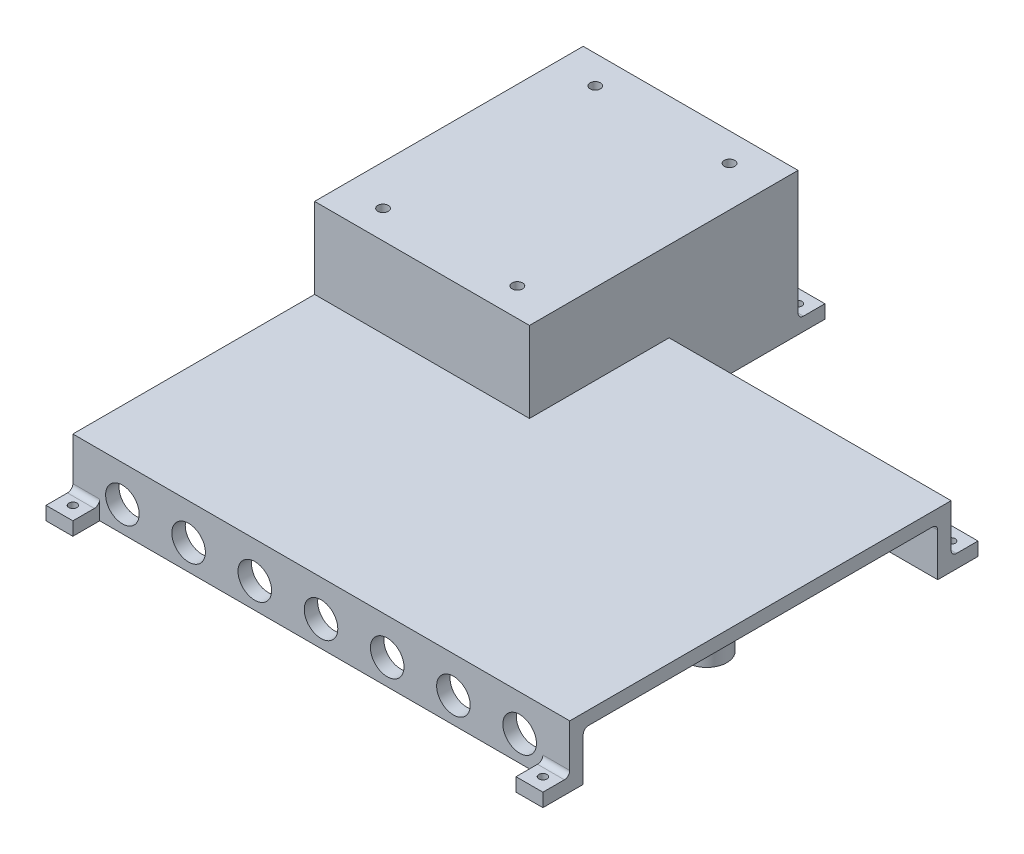
from build123d import *

# Parameters (mm, degrees)
SKETCH1_W            = 185
SKETCH1_H            = 142
BOSS_EXTRUDE1_DEPTH  = 23
SKETCH12_W           = 80
SKETCH12_H           = 100
BOSS_EXTRUDE6_DEPTH  = 53
SHELL1_T             = -5
SKETCH11_R           = 6.25
CUT_EXTRUDE2_DEPTH   = 6
FILLET1_R            = 2
SKETCH13_R           = 1.95
CUT_EXTRUDE3_DEPTH   = 54
SKETCH15_W           = 10
SKETCH15_H           = 5
BOSS_EXTRUDE8_DEPTH  = 10
SKETCH16_W           = 10
SKETCH16_H           = 5
BOSS_EXTRUDE9_DEPTH  = 10
SKETCH17_W           = 10
SKETCH17_H           = 5
BOSS_EXTRUDE10_DEPTH = 10
FILLET2_R            = 2
SKETCH18_R           = 1.5
CUT_EXTRUDE4_DEPTH   = 10
SKETCH19_R           = 7.5
BOSS_EXTRUDE11_DEPTH = 18
FILLET3_R            = 2


with BuildPart() as part:
    # Sketch1 → Boss-Extrude1 (new body)
    with BuildSketch(Plane(origin=(0, 0, 0), x_dir=(1, 0, 0), z_dir=(0, 1, 0))):
        with Locations((92.5, 71)):
            Rectangle(SKETCH1_W, SKETCH1_H)
    extrude(amount=BOSS_EXTRUDE1_DEPTH)

    # Sketch12 → Boss-Extrude6 (add)
    with BuildSketch(Plane(origin=(0, 0, 0), x_dir=(1, 0, 0), z_dir=(0, 1, 0))):
        with Locations((40, 140)):
            Rectangle(SKETCH12_W, SKETCH12_H)
    extrude(amount=BOSS_EXTRUDE6_DEPTH)

    # Shell1
    shell1_openings = [part.faces().sort_by_distance(p)[0] for p in [
        (88.333333333, 0, -110.666666667),
        (185, 11.5, -71),
        (0, 25.333333333, -93.333333333),
    ]]
    offset(amount=SHELL1_T, openings=shell1_openings, kind=Kind.INTERSECTION)

    # Sketch11 → Cut-Extrude2 (cut)
    with BuildSketch(Plane.XY):
        with Locations((18.4375, 9.5)):
            Circle(SKETCH11_R)
        with Locations((43.088852194, 9.5)):
            Circle(SKETCH11_R)
        with Locations((67.740204388, 9.5)):
            Circle(SKETCH11_R)
        with Locations((92.391556582, 9.5)):
            Circle(SKETCH11_R)
        with Locations((117.042908776, 9.5)):
            Circle(SKETCH11_R)
        with Locations((141.69426097, 9.5)):
            Circle(SKETCH11_R)
        with Locations((166.345613164, 9.5)):
            Circle(SKETCH11_R)
    extrude(amount=-CUT_EXTRUDE2_DEPTH, mode=Mode.SUBTRACT)

    # Fillet1
    fillet1_edges = [part.edges().sort_by_distance(p)[0] for p in [
        (92.5, 18, -5),
        (130, 18, -137),
        (37.5, 48, -95),
        (75, 48, -140),
        (37.5, 48, -185),
    ]]
    fillet(fillet1_edges, radius=FILLET1_R)

    # Sketch13 → Cut-Extrude3 (cut, through all)
    with BuildSketch(Plane(origin=(0, 53, 0), x_dir=(1, 0, 0), z_dir=(0, 1, 0))):
        with Locations((15, 100.5)):
            Circle(SKETCH13_R)
        with Locations((15, 179.5)):
            Circle(SKETCH13_R)
        with Locations((65, 179.5)):
            Circle(SKETCH13_R)
        with Locations((65, 100.5)):
            Circle(SKETCH13_R)
    extrude(amount=-CUT_EXTRUDE3_DEPTH, mode=Mode.SUBTRACT)

    # Sketch15 → Boss-Extrude8 (add)
    with BuildSketch(Plane.XY):
        with Locations((5, 2.5)):
            Rectangle(SKETCH15_W, SKETCH15_H)
        with Locations((180, 2.5)):
            Rectangle(SKETCH15_W, SKETCH15_H)
    extrude(amount=BOSS_EXTRUDE8_DEPTH)

    # Sketch16 → Boss-Extrude9 (add)
    with BuildSketch(Plane(origin=(0, 0, -190), x_dir=(-1, 0, 0), z_dir=(0, 0, -1))):
        with Locations((-5, 2.5)):
            Rectangle(SKETCH16_W, SKETCH16_H)
        with Locations((-75, 2.5)):
            Rectangle(SKETCH16_W, SKETCH16_H)
    extrude(amount=BOSS_EXTRUDE9_DEPTH)

    # Sketch17 → Boss-Extrude10 (add)
    with BuildSketch(Plane(origin=(0, 0, -142), x_dir=(-1, 0, 0), z_dir=(0, 0, -1))):
        with Locations((-180, 2.5)):
            Rectangle(SKETCH17_W, SKETCH17_H)
        with Locations((-85, 2.5)):
            Rectangle(SKETCH17_W, SKETCH17_H)
    extrude(amount=BOSS_EXTRUDE10_DEPTH)

    # Fillet2
    fillet2_edges = [part.edges().sort_by_distance(p)[0] for p in [
        (175, 2.5, -142),
        (180, 5, -142),
        (90, 2.5, -142),
        (85, 5, -142),
        (80, 5, -147),
        (80, 2.5, -152),
        (75, 5, -190),
        (70, 2.5, -190),
        (180, 5, 0),
        (5, 5, 0),
        (10, 2.5, -190),
        (5, 5, -190),
    ]]
    fillet(fillet2_edges, radius=FILLET2_R)

    # Sketch18 → Cut-Extrude4 (cut)
    with BuildSketch(Plane(origin=(0, 5, 0), x_dir=(1, 0, 0), z_dir=(0, 1, 0))):
        with Locations((180, 147)):
            Circle(SKETCH18_R)
        with Locations((85, 147)):
            Circle(SKETCH18_R)
        with Locations((5, -5)):
            Circle(SKETCH18_R)
        with Locations((180, -5)):
            Circle(SKETCH18_R)
        with Locations((75, 195)):
            Circle(SKETCH18_R)
        with Locations((5, 195)):
            Circle(SKETCH18_R)
    extrude(amount=-CUT_EXTRUDE4_DEPTH, mode=Mode.SUBTRACT)

    # Sketch19 → Boss-Extrude11 (add)
    with BuildSketch(Plane(origin=(0, 18, 0), x_dir=(-1, 0, 0), z_dir=(0, -1, 0))):
        with Locations((-165, 71)):
            Circle(SKETCH19_R)
        with Locations((-92.5, 71)):
            Circle(SKETCH19_R)
        with Locations((-20, 71)):
            Circle(SKETCH19_R)
    extrude(amount=BOSS_EXTRUDE11_DEPTH)

    # Fillet3
    fillet3_edges = [part.edges().sort_by_distance(p)[0] for p in [
        (172.5, 18, -71),
        (100, 18, -71),
        (27.5, 18, -71),
    ]]
    fillet(fillet3_edges, radius=FILLET3_R)


solid = part.part
